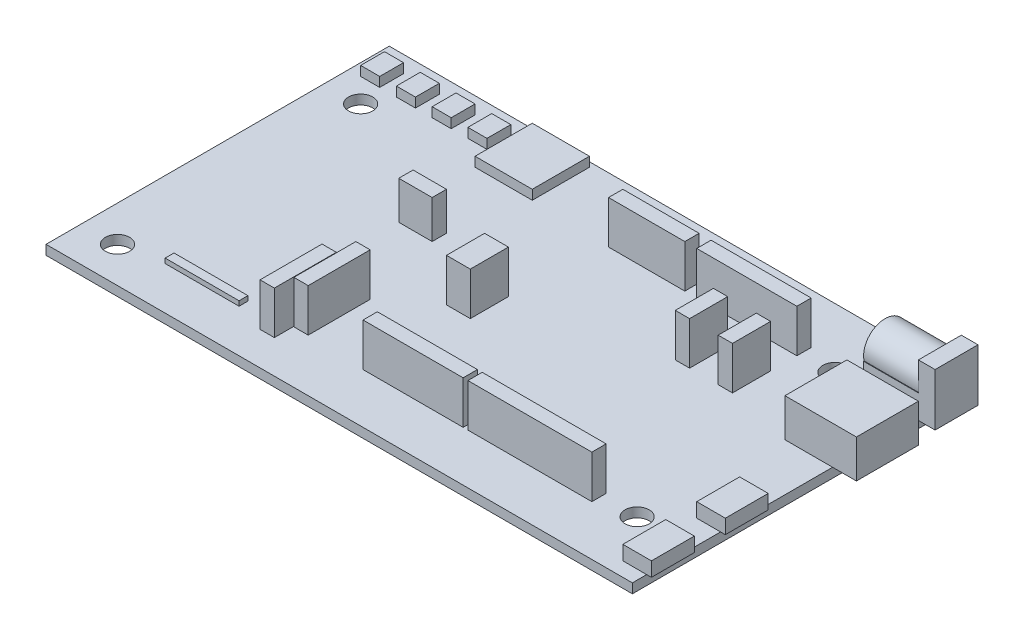
from build123d import *

# Parameters (mm, degrees)
SKETCH1_W            = 123
SKETCH1_H            = 72
BOSS_EXTRUDE1_DEPTH  = 2
SKETCH2_W            = 6
SKETCH2_H            = 9
BOSS_EXTRUDE2_DEPTH  = 3
SKETCH3_W            = 15
SKETCH3_H            = 9
BOSS_EXTRUDE3_DEPTH  = 5
SKETCH4_W            = 3.5
SKETCH4_H            = 9
BOSS_EXTRUDE4_DEPTH  = 6
SKETCH5_R            = 4.5
BOSS_EXTRUDE5_DEPTH  = 11.5
SKETCH6_W            = 15
SKETCH6_H            = 13
BOSS_EXTRUDE6_DEPTH  = 8
SKETCH7_W            = 26
SKETCH7_H            = 3
SKETCH7_W_2          = 21
SKETCH7_W_3          = 3
SKETCH7_H_2          = 8
SKETCH7_W_4          = 16
SKETCH7_W_5          = 5
SKETCH7_H_3          = 13
BOSS_EXTRUDE7_DEPTH  = 9
SKETCH8_W            = 12
SKETCH8_H            = 12
BOSS_EXTRUDE8_DEPTH  = 2
SKETCH9_W            = 4
SKETCH9_H            = 5
BOSS_EXTRUDE9_DEPTH  = 2
SKETCH11_W           = 7
SKETCH11_H           = 3
BOSS_EXTRUDE11_DEPTH = 8
SKETCH12_W           = 15.5
SKETCH12_H           = 1.85
BOSS_EXTRUDE12_DEPTH = 1
SKETCH13_R           = 2.54
CUT_EXTRUDE1_DEPTH   = 10


with BuildPart() as part:
    # Sketch1 → Boss-Extrude1 (new body)
    with BuildSketch(Plane(origin=(0, 0, 0), x_dir=(1, 0, 0), z_dir=(0, 1, 0))):
        Rectangle(SKETCH1_W, SKETCH1_H)
    extrude(amount=BOSS_EXTRUDE1_DEPTH)

    # Sketch2 → Boss-Extrude2 (add)
    with BuildSketch(Plane(origin=(0, 2, 0), x_dir=(1, 0, 0), z_dir=(0, 1, 0))):
        with Locations((59.5, -28.5)):
            Rectangle(SKETCH2_W, SKETCH2_H)
        with Locations((59.5, -13)):
            Rectangle(SKETCH2_W, SKETCH2_H)
    extrude(amount=BOSS_EXTRUDE2_DEPTH)

    # Sketch3 → Boss-Extrude3 (add)
    with BuildSketch(Plane(origin=(0, 2, 0), x_dir=(1, 0, 0), z_dir=(0, 1, 0))):
        with Locations((58, 28)):
            Rectangle(SKETCH3_W, SKETCH3_H)
    extrude(amount=BOSS_EXTRUDE3_DEPTH)

    # Sketch4 → Boss-Extrude4 (add)
    with BuildSketch(Plane(origin=(0, 7, 0), x_dir=(1, 0, 0), z_dir=(0, 1, 0))):
        with Locations((63.75, 28)):
            Rectangle(SKETCH4_W, SKETCH4_H)
    extrude(amount=BOSS_EXTRUDE4_DEPTH)

    # Sketch5 → Boss-Extrude5 (add)
    with BuildSketch(Plane.ZY.offset(-62)):
        with Locations((-28, 8)):
            Circle(SKETCH5_R)
    extrude(amount=BOSS_EXTRUDE5_DEPTH)

    # Sketch6 → Boss-Extrude6 (add)
    with BuildSketch(Plane(origin=(0, 2, 0), x_dir=(1, 0, 0), z_dir=(0, 1, 0))):
        with Locations((59, 12.5)):
            Rectangle(SKETCH6_W, SKETCH6_H)
    extrude(amount=BOSS_EXTRUDE6_DEPTH)

    # Sketch7 → Boss-Extrude7 (add)
    with BuildSketch(Plane(origin=(0, 2, 0), x_dir=(1, 0, 0), z_dir=(0, 1, 0))):
        with Locations((29.5, -24)):
            Rectangle(SKETCH7_W, SKETCH7_H)
        with Locations((5, -24)):
            Rectangle(SKETCH7_W_2, SKETCH7_H)
        with Locations((27, 24)):
            Rectangle(SKETCH7_W_2, SKETCH7_H)
        with Locations((36, 13)):
            Rectangle(SKETCH7_W_3, SKETCH7_H_2)
        with Locations((6, 24)):
            Rectangle(SKETCH7_W_4, SKETCH7_H)
        with Locations((27, 13)):
            Rectangle(SKETCH7_W_3, SKETCH7_H_2)
        with Locations((-6, -1)):
            Rectangle(SKETCH7_W_5, SKETCH7_H_2)
        with Locations((-19, -18.5)):
            Rectangle(SKETCH7_W_3, SKETCH7_H_3)
        with Locations((-22.1, -22.5)):
            Rectangle(SKETCH7_W_3, SKETCH7_H_3)
    extrude(amount=BOSS_EXTRUDE7_DEPTH)

    # Sketch8 → Boss-Extrude8 (add)
    with BuildSketch(Plane(origin=(0, 2, 0), x_dir=(1, 0, 0), z_dir=(0, 1, 0))):
        with Locations((-24.5, 29)):
            Rectangle(SKETCH8_W, SKETCH8_H)
    extrude(amount=BOSS_EXTRUDE8_DEPTH)

    # Sketch9 → Boss-Extrude9 (add)
    with BuildSketch(Plane(origin=(0, 2, 0), x_dir=(1, 0, 0), z_dir=(0, 1, 0))):
        with Locations((-42, 30)):
            Rectangle(SKETCH9_W, SKETCH9_H)
        with Locations((-49.5, 30)):
            Rectangle(SKETCH9_W, SKETCH9_H)
        with Locations((-57, 30)):
            Rectangle(SKETCH9_W, SKETCH9_H)
        with Locations((-34.5, 30)):
            Rectangle(SKETCH9_W, SKETCH9_H)
    extrude(amount=BOSS_EXTRUDE9_DEPTH)

    # Sketch11 → Boss-Extrude11 (add)
    with BuildSketch(Plane(origin=(0, 2, 0), x_dir=(1, 0, 0), z_dir=(0, 1, 0))):
        with Locations((-25, 6.5)):
            Rectangle(SKETCH11_W, SKETCH11_H)
    extrude(amount=BOSS_EXTRUDE11_DEPTH)

    # Sketch12 → Boss-Extrude12 (add)
    with BuildSketch(Plane(origin=(0, 2, 0), x_dir=(1, 0, 0), z_dir=(0, 1, 0))):
        with Locations((-37.75, -26.075)):
            Rectangle(SKETCH12_W, SKETCH12_H)
    extrude(amount=BOSS_EXTRUDE12_DEPTH)

    # Sketch13 → Cut-Extrude1 (cut)
    with BuildSketch(Plane(origin=(0, 2, 0), x_dir=(1, 0, 0), z_dir=(0, 1, 0))):
        with Locations((-54, -28.5)):
            Circle(SKETCH13_R)
        with Locations((-54, 22.5)):
            Circle(SKETCH13_R)
        with Locations((44.5, 23.5)):
            Circle(SKETCH13_R)
        with Locations((50, -23.5)):
            Circle(SKETCH13_R)
    extrude(amount=-CUT_EXTRUDE1_DEPTH, mode=Mode.SUBTRACT)


solid = part.part
